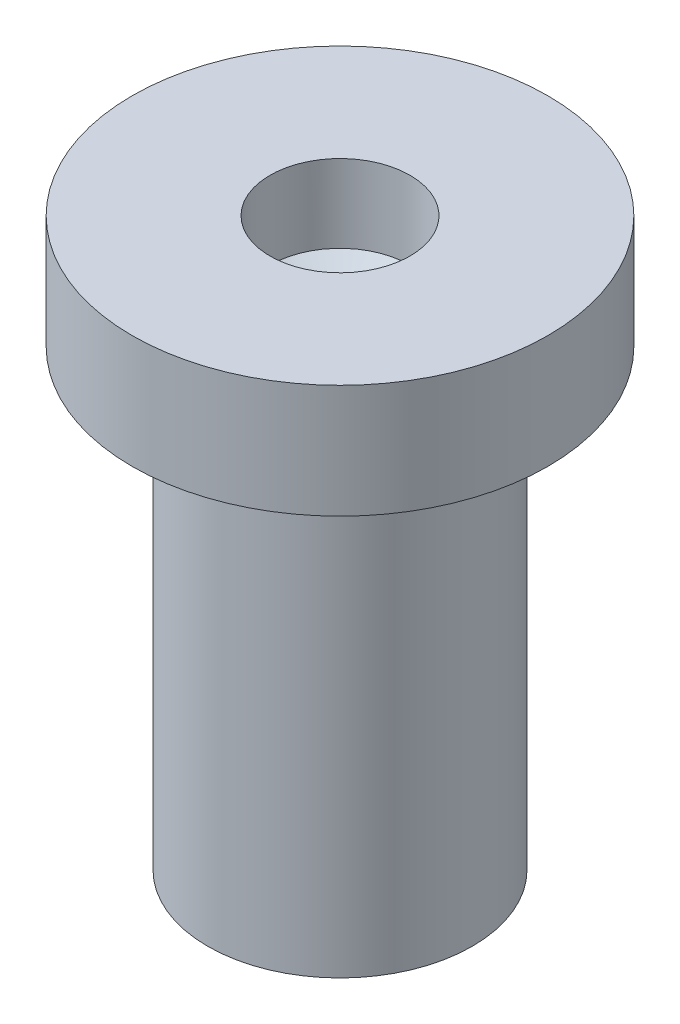
from build123d import *


with BuildPart() as part:
    # Sketch1 → Revolve1 (revolve)
    with BuildSketch(Plane.XY):
        Polygon((1.75, 0), (0, 0), (0, 6), (0.926555571, 6.470536499), (0.926555571, 7.5), (2.75, 7.5), (2.75, 6), (1.75, 6), align=None)
    revolve(axis=Axis((0, 0, 0), (0, 1, 0)))


solid = part.part
